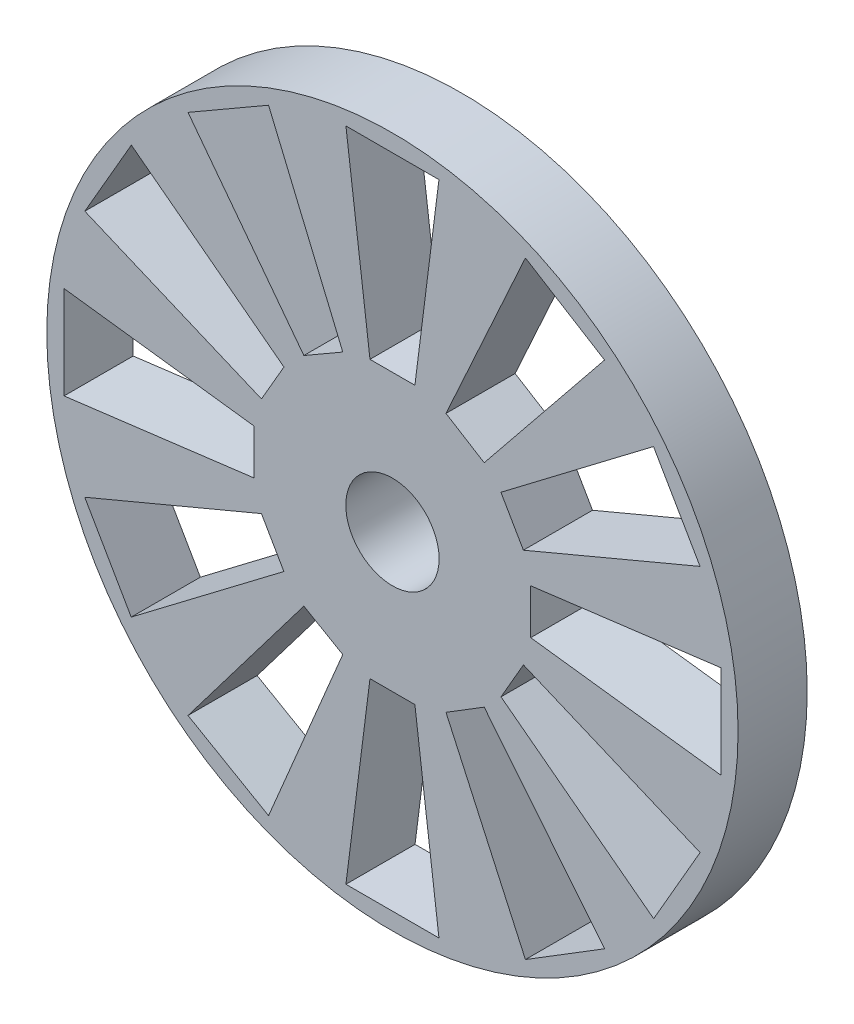
from build123d import *

# Parameters (mm, degrees)
ESBO_O1_R                = 10
ESBO_O1_R_2              = 1.35
RESSALTO_EXTRUS_O2_DEPTH = 2


with BuildPart() as part:
    # Esboço1 → Ressalto-extrusão2 (new body)
    with BuildSketch(Plane.XY):
        Circle(ESBO_O1_R)
        Circle(ESBO_O1_R_2, mode=Mode.SUBTRACT)
        Polygon((-1.345467814, 9.5), (1.345467814, 9.5), (0.65, 4), (0, 4), (-0.65, 4), align=None, mode=Mode.SUBTRACT)
        Polygon((2.655029784, 3.061587308), (6.136998996, 7.375467915), (3.847574626, 8.789565014), (1.549001215, 3.744742346), (2.102015499, 3.403164827), align=None, mode=Mode.SUBTRACT)
        Polygon((-1.436650808, 3.789265688), (-3.5837744, 8.900384525), (-5.914346634, 7.555182826), (-2.562558048, 3.139394249), (-1.999604428, 3.464329969), align=None, mode=Mode.SUBTRACT)
        Polygon((-3.463644773, 2.000791065), (-3.788773321, 1.43794879), (-8.899156331, 3.58682314), (-7.553156341, 5.91693442), (-3.138516225, 2.563633341), align=None, mode=Mode.SUBTRACT)
        Polygon((-3.999999765, 0.001370256), (-4.000222432, -0.648629706), (-9.500460351, -1.342213377), (-9.499538534, 1.348722092), (-3.999777099, 0.651370218), align=None, mode=Mode.SUBTRACT)
        Polygon((-3.465014758, -1.998417556), (-3.140271905, -2.561482454), (-7.557208424, -5.911758154), (-8.901611674, -3.580725239), (-3.789757611, -1.435352658), align=None, mode=Mode.SUBTRACT)
        Polygon((-1.999604428, -3.464329969), (-1.436650808, -3.789265688), (-3.5837744, -8.900384525), (-5.914346634, -7.555182826), (-2.562558048, -3.139394249), align=None, mode=Mode.SUBTRACT)
        Polygon((-0.65, -4), (-1.345467814, -9.5), (1.345467814, -9.5), (0.65, -4), (0, -4), align=None, mode=Mode.SUBTRACT)
        Polygon((2.102015499, -3.403164827), (2.655029784, -3.061587308), (6.136998996, -7.375467915), (3.847574626, -8.789565014), (1.549001215, -3.744742346), align=None, mode=Mode.SUBTRACT)
        Polygon((3.465014758, -1.998417556), (3.789757611, -1.435352658), (8.901611674, -3.580725239), (7.557208424, -5.911758154), (3.140271905, -2.561482454), align=None, mode=Mode.SUBTRACT)
        Polygon((3.999999765, 0.001370256), (3.999777099, 0.651370218), (9.499538534, 1.348722092), (9.500460351, -1.342213377), (4.000222432, -0.648629706), align=None, mode=Mode.SUBTRACT)
        Polygon((3.463644773, 2.000791065), (3.138516225, 2.563633341), (7.553156341, 5.91693442), (8.899156331, 3.58682314), (3.788773321, 1.43794879), align=None, mode=Mode.SUBTRACT)
    extrude(amount=RESSALTO_EXTRUS_O2_DEPTH)


solid = part.part
